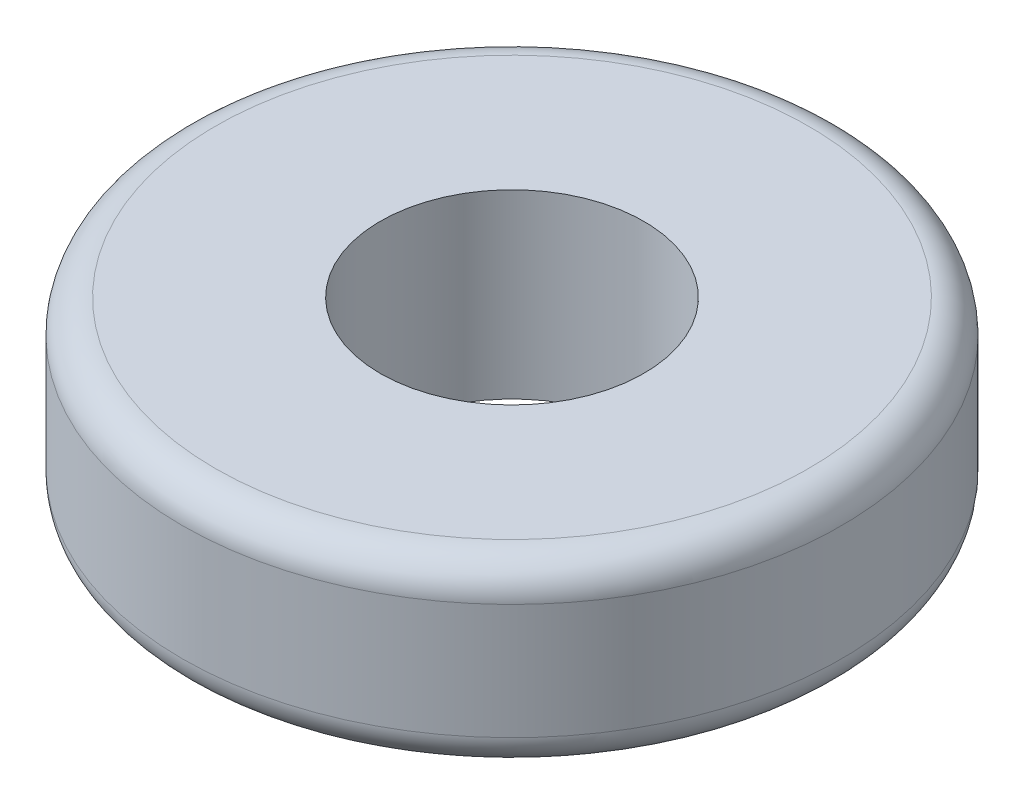
from build123d import *

# Parameters (mm, degrees)
SKETCH1_R           = 10
SKETCH1_R_2         = 4
BOSS_EXTRUDE1_DEPTH = 5.5
FILLET1_R           = 1


with BuildPart() as part:
    # Sketch1 → Boss-Extrude1 (new body)
    with BuildSketch(Plane(origin=(0, 0, 0), x_dir=(1, 0, 0), z_dir=(0, 1, 0))):
        Circle(SKETCH1_R)
        Circle(SKETCH1_R_2, mode=Mode.SUBTRACT)
    extrude(amount=BOSS_EXTRUDE1_DEPTH)

    # Fillet1
    fillet1_edges = [part.edges().sort_by_distance(p)[0] for p in [
        (-10, 0, 0),
        (-10, 5.5, 0),
    ]]
    fillet(fillet1_edges, radius=FILLET1_R)


solid = part.part
